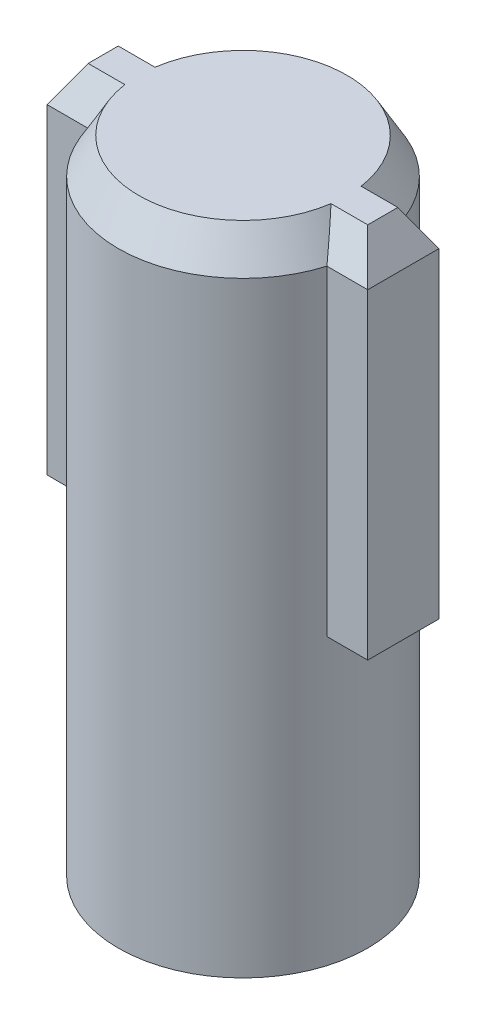
from build123d import *
from OCP.BRepFilletAPI import BRepFilletAPI_MakeChamfer

# Parameters (mm, degrees)
SKETCH1_R           = 3.5
BOSS_EXTRUDE1_DEPTH = 18
SKETCH2_W           = 9
SKETCH2_H           = 2
BOSS_EXTRUDE3_DEPTH = 10
CUT_EXTRUDE3_START  = -8
SKETCH3_W           = 10
SKETCH3_H           = 2.5
CUT_EXTRUDE3_DEPTH  = 4
CHAMFER1_SIZE       = 1
CHAMFER1_SIZE2      = 0.577350269


with BuildPart() as part:
    # Sketch1 → Boss-Extrude1 (new body)
    with BuildSketch(Plane(origin=(0, 0, 0), x_dir=(1, 0, 0), z_dir=(0, 1, 0))):
        with Locations(Location((0, 0, 0), (0, 0, 270))):
            Circle(SKETCH1_R)
    extrude(amount=BOSS_EXTRUDE1_DEPTH)

    # Sketch2 → Boss-Extrude3 (add)
    with BuildSketch(Plane(origin=(0, 18, 0), x_dir=(1, 0, 0), z_dir=(0, 1, 0))):
        Rectangle(SKETCH2_W, SKETCH2_H)
    extrude(amount=-BOSS_EXTRUDE3_DEPTH)

    # Sketch3 → Cut-Extrude3 (cut)
    with BuildSketch(Plane.XZ.offset(CUT_EXTRUDE3_START)):
        with Locations((0, -2.25)):
            Rectangle(SKETCH3_W, SKETCH3_H)
    extrude(amount=-CUT_EXTRUDE3_DEPTH, mode=Mode.SUBTRACT)

    # Chamfer1: one chamfer whose edges measure the first distance from different faces: ONE call of the kernel's chamfer builder (chamfer() names one face for all edges)
    chamfer1_edges_1 = [part.edges().sort_by_distance(p)[0] for p in [
        (3.927050983, 18, -1),
        (-3.927050983, 18, -1),
    ]]
    chamfer1_side_1 = [part.faces().sort_by_distance(p)[0] for p in [
        (0, 11.381966011, -1),
    ]]
    chamfer1_edges_2 = [part.edges().sort_by_distance(p)[0] for p in [
        (3.927050983, 18, 1),
    ]]
    chamfer1_side_2 = [part.faces().sort_by_distance(p)[0] for p in [
        (3.927050983, 13, 1),
    ]]
    chamfer1_edges_3 = [part.edges().sort_by_distance(p)[0] for p in [
        (4.5, 18, 0),
    ]]
    chamfer1_side_3 = [part.faces().sort_by_distance(p)[0] for p in [
        (4.5, 13, 0),
    ]]
    chamfer1_edges_4 = [part.edges().sort_by_distance(p)[0] for p in [
        (-3.927050983, 18, 1),
    ]]
    chamfer1_side_4 = [part.faces().sort_by_distance(p)[0] for p in [
        (-3.927050983, 13, 1),
    ]]
    chamfer1_edges_5 = [part.edges().sort_by_distance(p)[0] for p in [
        (-4.5, 18, 0),
    ]]
    chamfer1_side_5 = [part.faces().sort_by_distance(p)[0] for p in [
        (-4.5, 13, 0),
    ]]
    chamfer1_edges_6 = [part.edges().sort_by_distance(p)[0] for p in [
        (0, 18, -3.5),
    ]]
    chamfer1_side_6 = [part.faces().sort_by_distance(p)[0] for p in [
        (0, 15, -3.5),
    ]]
    chamfer1_edges_7 = [part.edges().sort_by_distance(p)[0] for p in [
        (2.091650066, 18, 2.80624304),
    ]]
    chamfer1_side_7 = [part.faces().sort_by_distance(p)[0] for p in [
        (0, 9, -3.5),
    ]]
    chamfer1 = BRepFilletAPI_MakeChamfer(part.part.solid().wrapped)
    for e in chamfer1_edges_1:
        chamfer1.Add(CHAMFER1_SIZE, CHAMFER1_SIZE2, e.wrapped, chamfer1_side_1[0].wrapped)  # the first distance lies on this face
    for e in chamfer1_edges_2:
        chamfer1.Add(CHAMFER1_SIZE, CHAMFER1_SIZE2, e.wrapped, chamfer1_side_2[0].wrapped)  # the first distance lies on this face
    for e in chamfer1_edges_3:
        chamfer1.Add(CHAMFER1_SIZE, CHAMFER1_SIZE2, e.wrapped, chamfer1_side_3[0].wrapped)  # the first distance lies on this face
    for e in chamfer1_edges_4:
        chamfer1.Add(CHAMFER1_SIZE, CHAMFER1_SIZE2, e.wrapped, chamfer1_side_4[0].wrapped)  # the first distance lies on this face
    for e in chamfer1_edges_5:
        chamfer1.Add(CHAMFER1_SIZE, CHAMFER1_SIZE2, e.wrapped, chamfer1_side_5[0].wrapped)  # the first distance lies on this face
    for e in chamfer1_edges_6:
        chamfer1.Add(CHAMFER1_SIZE, CHAMFER1_SIZE2, e.wrapped, chamfer1_side_6[0].wrapped)  # the first distance lies on this face
    for e in chamfer1_edges_7:
        chamfer1.Add(CHAMFER1_SIZE, CHAMFER1_SIZE2, e.wrapped, chamfer1_side_7[0].wrapped)  # the first distance lies on this face
    add(Compound.cast(chamfer1.Shape()), mode=Mode.REPLACE)


solid = part.part
